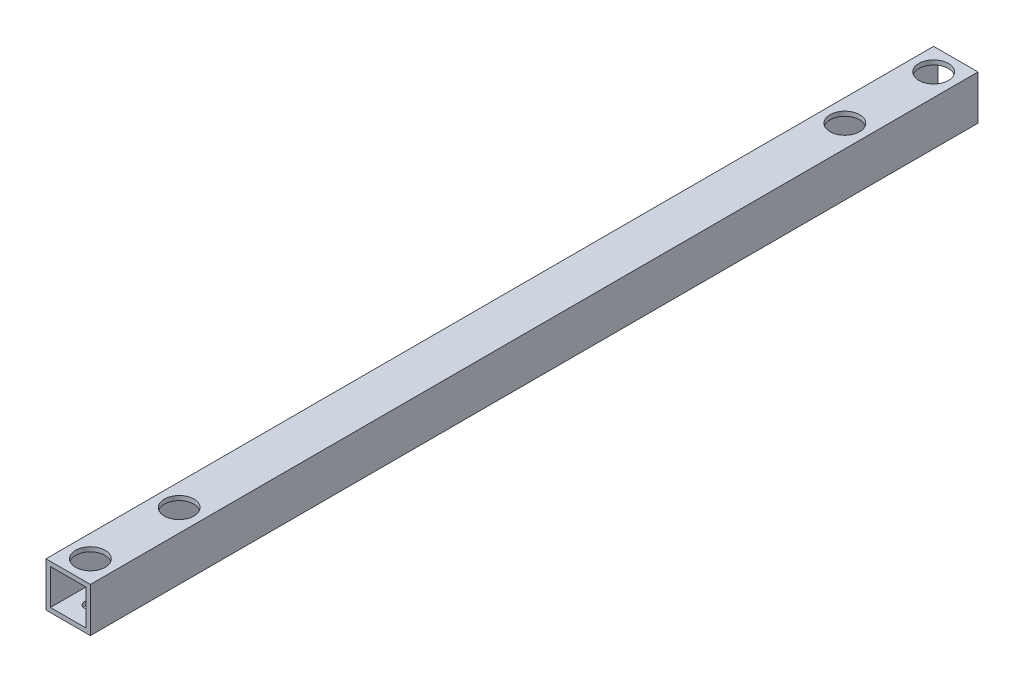
from build123d import *

# Parameters (mm, degrees)
SKETCH_1_W          = 15
SKETCH_1_H          = 15
SKETCH_1_W_2        = 12
SKETCH_1_H_2        = 12
EXTRUDE_1_DEPTH     = 300
SKETCH_5_R          = 2
CUT_EXTRUDE_4_DEPTH = 20
SKETCH_8_R          = 5
CUT_EXTRUDE_5_DEPTH = 10


with BuildPart() as part:
    # ｽｹｯﾁ1 → ﾎﾞｽ - 押し出し1 (new body)
    with BuildSketch(Plane.XY):
        Rectangle(SKETCH_1_W, SKETCH_1_H)
        Rectangle(SKETCH_1_W_2, SKETCH_1_H_2, mode=Mode.SUBTRACT)
    extrude(amount=EXTRUDE_1_DEPTH)

    # ｽｹｯﾁ5 → ｶｯﾄ - 押し出し4 (cut)
    with BuildSketch(Plane(origin=(0, -7.5, 0), x_dir=(-1, 0, 0), z_dir=(0, -1, 0))):
        with Locations((0, -37.5)):
            Circle(SKETCH_5_R)
        with Locations((0, -7.5)):
            Circle(SKETCH_5_R)
        with Locations((0, -292.5)):
            Circle(SKETCH_5_R)
        with Locations((0, -262.5)):
            Circle(SKETCH_5_R)
    extrude(amount=-CUT_EXTRUDE_4_DEPTH, mode=Mode.SUBTRACT)

    # ｽｹｯﾁ8 → ｶｯﾄ - 押し出し5 (cut)
    with BuildSketch(Plane(origin=(0, 7.5, 0), x_dir=(1, 0, 0), z_dir=(0, 1, 0))):
        with Locations((0, -292.5)):
            Circle(SKETCH_8_R)
        with Locations((0, -262.5)):
            Circle(SKETCH_8_R)
        with Locations((0, -37.5)):
            Circle(SKETCH_8_R)
        with Locations((0, -7.5)):
            Circle(SKETCH_8_R)
    extrude(amount=-CUT_EXTRUDE_5_DEPTH, mode=Mode.SUBTRACT)


solid = part.part
